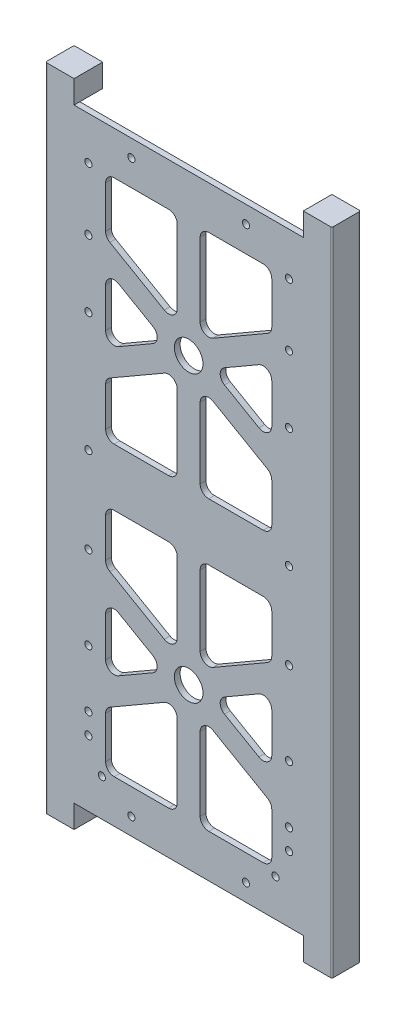
from build123d import *

# Parameters (mm, degrees)
SKETCH1_W                       = 88
SKETCH1_H                       = 211
BOSS_EXTRUDE1_DEPTH             = 2
CUT_EXTRUDE2_DEPTH              = 2
SKETCH4_R                       = 5
CUT_EXTRUDE3_DEPTH              = 3
FILLET2_R                       = 3
BOSS_EXTRUDE2_DEPTH             = 10
CUT_EXTRUDE5_DEPTH              = 8
M3X0_5_TAPPED_HOLE1_AT_2_COUNT  = 2
M3X0_5_TAPPED_HOLE1_AT_2_PITCH  = 23.4
M3X0_5_TAPPED_HOLE1_AT_3_COUNT  = 2
M3X0_5_TAPPED_HOLE1_AT_3_PITCH  = 65.1
M3X0_5_TAPPED_HOLE1_AT_4_COUNT  = 2
M3X0_5_TAPPED_HOLE1_AT_4_PITCH  = 95.1
M3X0_5_TAPPED_HOLE1_AT_5_COUNT  = 2
M3X0_5_TAPPED_HOLE1_AT_5_PITCH  = 124.1
M3X0_5_TAPPED_HOLE1_AT_6_COUNT  = 2
M3X0_5_TAPPED_HOLE1_AT_6_PITCH  = 144.1
M3X0_5_TAPPED_HOLE1_AT_7_COUNT  = 2
M3X0_5_TAPPED_HOLE1_AT_7_PITCH  = 161.368460363
M3X0_5_TAPPED_HOLE1_AT_8_COUNT  = 2
M3X0_5_TAPPED_HOLE1_AT_8_PITCH  = 34.168552793
M3X0_5_TAPPED_HOLE1_AT_9_COUNT  = 2
M3X0_5_TAPPED_HOLE1_AT_9_PITCH  = 168.96712698
M3X0_5_TAPPED_HOLE1_AT_10_COUNT = 2
M3X0_5_TAPPED_HOLE1_AT_10_PITCH = 151.3
M3X0_5_TAPPED_HOLE1_AT_11_COUNT = 2
M3X0_5_TAPPED_HOLE1_AT_11_PITCH = 21.7
SKETCH58_R                      = 1.665
CUT_EXTRUDE9_DEPTH              = 1.8
SKETCH59_R                      = 2
CUT_EXTRUDE10_DEPTH             = 10
FILLET3_R                       = 0.5


with BuildPart() as part:
    # Sketch1 → Boss-Extrude1 (new body)
    with BuildSketch(Plane.XY):
        with Locations((44, 105.5)):
            Rectangle(SKETCH1_W, SKETCH1_H)
    extrude(amount=BOSS_EXTRUDE1_DEPTH)

    # Sketch3 → Cut-Extrude2 (cut)
    with BuildSketch(Plane.XY.offset(2)):
        Polygon((73, 115.5), (73, 133.88804004), (48, 148.32179677), (48, 115.5), align=None)
        Polygon((40, 148.32179677), (15, 133.88804004), (15, 115.5), (40, 115.5), align=None)
        Polygon((36, 155.25), (15, 167.374355653), (15, 143.125644347), align=None)
        Polygon((73, 143.125644347), (73, 167.374355653), (52, 155.25), align=None)
        Polygon((73, 196), (48, 196), (48, 162.17820323), (73, 176.61195996), align=None)
        Polygon((40, 196), (15, 196), (15, 176.61195996), (40, 162.17820323), align=None)
    cut_extrude2 = extrude(amount=-CUT_EXTRUDE2_DEPTH, mode=Mode.SUBTRACT)

    # Sketch4 → Cut-Extrude3 (cut, through all)
    with BuildSketch(Plane.XY.offset(2)):
        with Locations((44, 155.25)):
            Circle(SKETCH4_R)
    cut_extrude3 = extrude(amount=-CUT_EXTRUDE3_DEPTH, mode=Mode.SUBTRACT)

    # Mirror2: Cut-Extrude2, Cut-Extrude3 across plane
    add(cut_extrude2.mirror(Plane(origin=(0, 105.5, 0), x_dir=(0, 0, 1), z_dir=(0, -1, 0))), mode=Mode.SUBTRACT)
    add(cut_extrude3.mirror(Plane(origin=(0, 105.5, 0), x_dir=(0, 0, 1), z_dir=(0, -1, 0))), mode=Mode.SUBTRACT)

    # Fillet2
    fillet2_edges = [part.edges().sort_by_distance(p)[0] for p in [
        (36, 55.75, 1),
        (15, 43.625644347, 1),
        (15, 67.874355653, 1),
        (40, 95.5, 1),
        (40, 62.67820323, 1),
        (15, 77.11195996, 1),
        (15, 95.5, 1),
        (48, 48.82179677, 1),
        (73, 34.38804004, 1),
        (73, 15, 1),
        (48, 15, 1),
        (73, 43.625644347, 1),
        (52, 55.75, 1),
        (73, 67.874355653, 1),
        (15, 15, 1),
        (15, 34.38804004, 1),
        (40, 48.82179677, 1),
        (40, 15, 1),
        (73, 77.11195996, 1),
        (48, 62.67820323, 1),
        (48, 95.5, 1),
        (73, 95.5, 1),
        (15, 167.374355653, 1),
        (36, 155.25, 1),
        (15, 143.125644347, 1),
        (40, 148.32179677, 1),
        (40, 115.5, 1),
        (15, 115.5, 1),
        (15, 133.88804004, 1),
        (73, 176.61195996, 1),
        (48, 162.17820323, 1),
        (48, 196, 1),
        (73, 196, 1),
        (52, 155.25, 1),
        (73, 167.374355653, 1),
        (73, 143.125644347, 1),
        (15, 176.61195996, 1),
        (15, 196, 1),
        (40, 196, 1),
        (40, 162.17820323, 1),
        (48, 148.32179677, 1),
        (73, 133.88804004, 1),
        (73, 115.5, 1),
        (48, 115.5, 1),
    ]]
    fillet(fillet2_edges, radius=FILLET2_R)

    # Sketch7 → Boss-Extrude2 (add)
    with BuildSketch(Plane.XY.offset(2)):
        Polygon((94, 219), (84, 219), (84, 211), (88, 211), (88, 0), (84, 0), (84, -8), (94, -8), align=None)
        Polygon((-6, -8), (4, -8), (4, 0), (0, 0), (0, 211), (4, 211), (4, 219), (-6, 219), align=None)
    extrude(amount=-BOSS_EXTRUDE2_DEPTH)

    # Sketch53 → Cut-Extrude5 (cut)
    with BuildSketch(Plane(origin=(0, 0, -8), x_dir=(-1, 0, 0), z_dir=(0, 0, -1))):
        with BuildLine():
            Line((-90, 0), (-88, 0))
            Line((-88, 0), (-88, 211))
            Line((-88, 211), (-90, 211))
            ThreePointArc((-90, 211), (-91.414213562, 210.414213562), (-92, 209))
            Line((-92, 209), (-92, 2))
            ThreePointArc((-92, 2), (-91.414213562, 0.585786438), (-90, 0))
        make_face()
        with BuildLine():
            Line((2, 0), (-4, 0))
            Line((-4, 0), (-4, 211))
            Line((-4, 211), (2, 211))
            ThreePointArc((2, 211), (3.414213562, 210.414213562), (4, 209))
            Line((4, 209), (4, 2))
            ThreePointArc((4, 2), (3.414213562, 0.585786438), (2, 0))
        make_face()
    extrude(amount=-CUT_EXTRUDE5_DEPTH, mode=Mode.SUBTRACT)

    # Sketch56 → M3x0.5 Tapped Hole1 (revolve, cut)
    with BuildSketch(Plane(origin=(9, 174.3, 2), x_dir=(0, -1, 0), z_dir=(1, 0, 0))):
        Polygon((0, 0), (0, 10.751075774), (1.25, 10), (1.25, 0), align=None)
    m3x0_5_tapped_hole1 = revolve(axis=Axis((9, 174.3, 8.35), (0, 0, -1)), mode=Mode.SUBTRACT)

    # M3x0.5 Tapped Hole1 at 2: M3x0.5 Tapped Hole1 ×2
    with Locations(*[(0, -i * M3X0_5_TAPPED_HOLE1_AT_2_PITCH, 0) for i in range(1, M3X0_5_TAPPED_HOLE1_AT_2_COUNT)]):
        add(m3x0_5_tapped_hole1, mode=Mode.SUBTRACT)

    # M3x0.5 Tapped Hole1 at 3: M3x0.5 Tapped Hole1 ×2
    with Locations(*[(0, -i * M3X0_5_TAPPED_HOLE1_AT_3_PITCH, 0) for i in range(1, M3X0_5_TAPPED_HOLE1_AT_3_COUNT)]):
        add(m3x0_5_tapped_hole1, mode=Mode.SUBTRACT)

    # M3x0.5 Tapped Hole1 at 4: M3x0.5 Tapped Hole1 ×2
    with Locations(*[(0, -i * M3X0_5_TAPPED_HOLE1_AT_4_PITCH, 0) for i in range(1, M3X0_5_TAPPED_HOLE1_AT_4_COUNT)]):
        add(m3x0_5_tapped_hole1, mode=Mode.SUBTRACT)

    # M3x0.5 Tapped Hole1 at 5: M3x0.5 Tapped Hole1 ×2
    with Locations(*[(0, -i * M3X0_5_TAPPED_HOLE1_AT_5_PITCH, 0) for i in range(1, M3X0_5_TAPPED_HOLE1_AT_5_COUNT)]):
        add(m3x0_5_tapped_hole1, mode=Mode.SUBTRACT)

    # M3x0.5 Tapped Hole1 at 6: M3x0.5 Tapped Hole1 ×2
    with Locations(*[(0, -i * M3X0_5_TAPPED_HOLE1_AT_6_PITCH, 0) for i in range(1, M3X0_5_TAPPED_HOLE1_AT_6_COUNT)]):
        add(m3x0_5_tapped_hole1, mode=Mode.SUBTRACT)

    # M3x0.5 Tapped Hole1 at 7: M3x0.5 Tapped Hole1 ×2
    with Locations(*[Vector(0.02912589, -0.999575751, 0) * (i * M3X0_5_TAPPED_HOLE1_AT_7_PITCH) for i in range(1, M3X0_5_TAPPED_HOLE1_AT_7_COUNT)]):
        add(m3x0_5_tapped_hole1, mode=Mode.SUBTRACT)

    # M3x0.5 Tapped Hole1 at 8: M3x0.5 Tapped Hole1 ×2
    with Locations(*[Vector(0.439000156, 0.898486986, 0) * (i * M3X0_5_TAPPED_HOLE1_AT_8_PITCH) for i in range(1, M3X0_5_TAPPED_HOLE1_AT_8_COUNT)]):
        add(m3x0_5_tapped_hole1, mode=Mode.SUBTRACT)

    # M3x0.5 Tapped Hole1 at 9: M3x0.5 Tapped Hole1 ×2
    with Locations(*[Vector(0.088774664, -0.996051735, 0) * (i * M3X0_5_TAPPED_HOLE1_AT_9_PITCH) for i in range(1, M3X0_5_TAPPED_HOLE1_AT_9_COUNT)]):
        add(m3x0_5_tapped_hole1, mode=Mode.SUBTRACT)

    # M3x0.5 Tapped Hole1 at 10: M3x0.5 Tapped Hole1 ×2
    with Locations(*[(0, -i * M3X0_5_TAPPED_HOLE1_AT_10_PITCH, 0) for i in range(1, M3X0_5_TAPPED_HOLE1_AT_10_COUNT)]):
        add(m3x0_5_tapped_hole1, mode=Mode.SUBTRACT)

    # M3x0.5 Tapped Hole1 at 11: M3x0.5 Tapped Hole1 ×2
    with Locations(*[(0, i * M3X0_5_TAPPED_HOLE1_AT_11_PITCH, 0) for i in range(1, M3X0_5_TAPPED_HOLE1_AT_11_COUNT)]):
        add(m3x0_5_tapped_hole1, mode=Mode.SUBTRACT)

    # Mirror3: M3x0.5 Tapped Hole1 across plane
    add(m3x0_5_tapped_hole1.mirror(Plane.ZY.offset(-44)), mode=Mode.SUBTRACT)

    # Mirror3 copy 1 sketch → Mirror3 copy 1 (revolve, cut)
    with BuildSketch(Plane(origin=(79, 150.9, 2), x_dir=(0, -1, 0), z_dir=(-1, 0, 0))):
        Polygon((0, 0), (0, -10.751075774), (1.25, -10), (1.25, 0), align=None)
    revolve(axis=Axis((79, 150.9, 8.35), (0, 0, 1)), mode=Mode.SUBTRACT)

    # Mirror3 copy 2 sketch → Mirror3 copy 2 (revolve, cut)
    with BuildSketch(Plane(origin=(79, 109.2, 2), x_dir=(0, -1, 0), z_dir=(-1, 0, 0))):
        Polygon((0, 0), (0, -10.751075774), (1.25, -10), (1.25, 0), align=None)
    revolve(axis=Axis((79, 109.2, 8.35), (0, 0, 1)), mode=Mode.SUBTRACT)

    # Mirror3 copy 3 sketch → Mirror3 copy 3 (revolve, cut)
    with BuildSketch(Plane(origin=(79, 79.2, 2), x_dir=(0, -1, 0), z_dir=(-1, 0, 0))):
        Polygon((0, 0), (0, -10.751075774), (1.25, -10), (1.25, 0), align=None)
    revolve(axis=Axis((79, 79.2, 8.35), (0, 0, 1)), mode=Mode.SUBTRACT)

    # Mirror3 copy 4 sketch → Mirror3 copy 4 (revolve, cut)
    with BuildSketch(Plane(origin=(79, 50.2, 2), x_dir=(0, -1, 0), z_dir=(-1, 0, 0))):
        Polygon((0, 0), (0, -10.751075774), (1.25, -10), (1.25, 0), align=None)
    revolve(axis=Axis((79, 50.2, 8.35), (0, 0, 1)), mode=Mode.SUBTRACT)

    # Mirror3 copy 5 sketch → Mirror3 copy 5 (revolve, cut)
    with BuildSketch(Plane(origin=(79, 30.2, 2), x_dir=(0, -1, 0), z_dir=(-1, 0, 0))):
        Polygon((0, 0), (0, -10.751075774), (1.25, -10), (1.25, 0), align=None)
    revolve(axis=Axis((79, 30.2, 8.35), (0, 0, 1)), mode=Mode.SUBTRACT)

    # Mirror3 copy 6 sketch → Mirror3 copy 6 (revolve, cut)
    with BuildSketch(Plane(origin=(74.3, 13, 2), x_dir=(0, -1, 0), z_dir=(-1, 0, 0))):
        Polygon((0, 0), (0, -10.751075774), (1.25, -10), (1.25, 0), align=None)
    revolve(axis=Axis((74.3, 13, 8.35), (0, 0, 1)), mode=Mode.SUBTRACT)

    # Mirror3 copy 7 sketch → Mirror3 copy 7 (revolve, cut)
    with BuildSketch(Plane(origin=(64, 205, 2), x_dir=(0, -1, 0), z_dir=(-1, 0, 0))):
        Polygon((0, 0), (0, -10.751075774), (1.25, -10), (1.25, 0), align=None)
    revolve(axis=Axis((64, 205, 8.35), (0, 0, 1)), mode=Mode.SUBTRACT)

    # Mirror3 copy 8 sketch → Mirror3 copy 8 (revolve, cut)
    with BuildSketch(Plane(origin=(64, 6, 2), x_dir=(0, -1, 0), z_dir=(-1, 0, 0))):
        Polygon((0, 0), (0, -10.751075774), (1.25, -10), (1.25, 0), align=None)
    revolve(axis=Axis((64, 6, 8.35), (0, 0, 1)), mode=Mode.SUBTRACT)

    # Mirror3 copy 9 sketch → Mirror3 copy 9 (revolve, cut)
    with BuildSketch(Plane(origin=(79, 23, 2), x_dir=(0, -1, 0), z_dir=(-1, 0, 0))):
        Polygon((0, 0), (0, -10.751075774), (1.25, -10), (1.25, 0), align=None)
    revolve(axis=Axis((79, 23, 8.35), (0, 0, 1)), mode=Mode.SUBTRACT)

    # Mirror3 copy 10 sketch → Mirror3 copy 10 (revolve, cut)
    with BuildSketch(Plane(origin=(79, 196, 2), x_dir=(0, -1, 0), z_dir=(-1, 0, 0))):
        Polygon((0, 0), (0, -10.751075774), (1.25, -10), (1.25, 0), align=None)
    revolve(axis=Axis((79, 196, 8.35), (0, 0, 1)), mode=Mode.SUBTRACT)

    # Sketch58 → Cut-Extrude9 (cut)
    with BuildSketch(Plane(origin=(0, 0, 0), x_dir=(-1, 0, 0), z_dir=(0, 0, -1))):
        with Locations((-0.7, 13)):
            Circle(SKETCH58_R)
    cut_extrude9 = extrude(amount=-CUT_EXTRUDE9_DEPTH, mode=Mode.SUBTRACT)

    # Mirror4: Cut-Extrude9 across plane
    add(cut_extrude9.mirror(Plane(origin=(44, 0, 0), x_dir=(0, 0, 1), z_dir=(1, 0, 0))), mode=Mode.SUBTRACT)

    # Sketch59 → Cut-Extrude10 (cut)
    with BuildSketch(Plane(origin=(0, -8, 0), x_dir=(-1, 0, 0), z_dir=(0, -1, 0))):
        with Locations((-89, 2.4)):
            Circle(SKETCH59_R)
        with Locations((1, 2.4)):
            Circle(SKETCH59_R)
    extrude(amount=-CUT_EXTRUDE10_DEPTH, mode=Mode.SUBTRACT)

    # Fillet3
    fillet3_edges = [part.edges().sort_by_distance(p)[0] for p in [
        (94, 105.5, -8),
        (94, 105.5, 2),
        (-6, 105.5, -8),
        (-6, 105.5, 2),
    ]]
    fillet(fillet3_edges, radius=FILLET3_R)


solid = part.part
